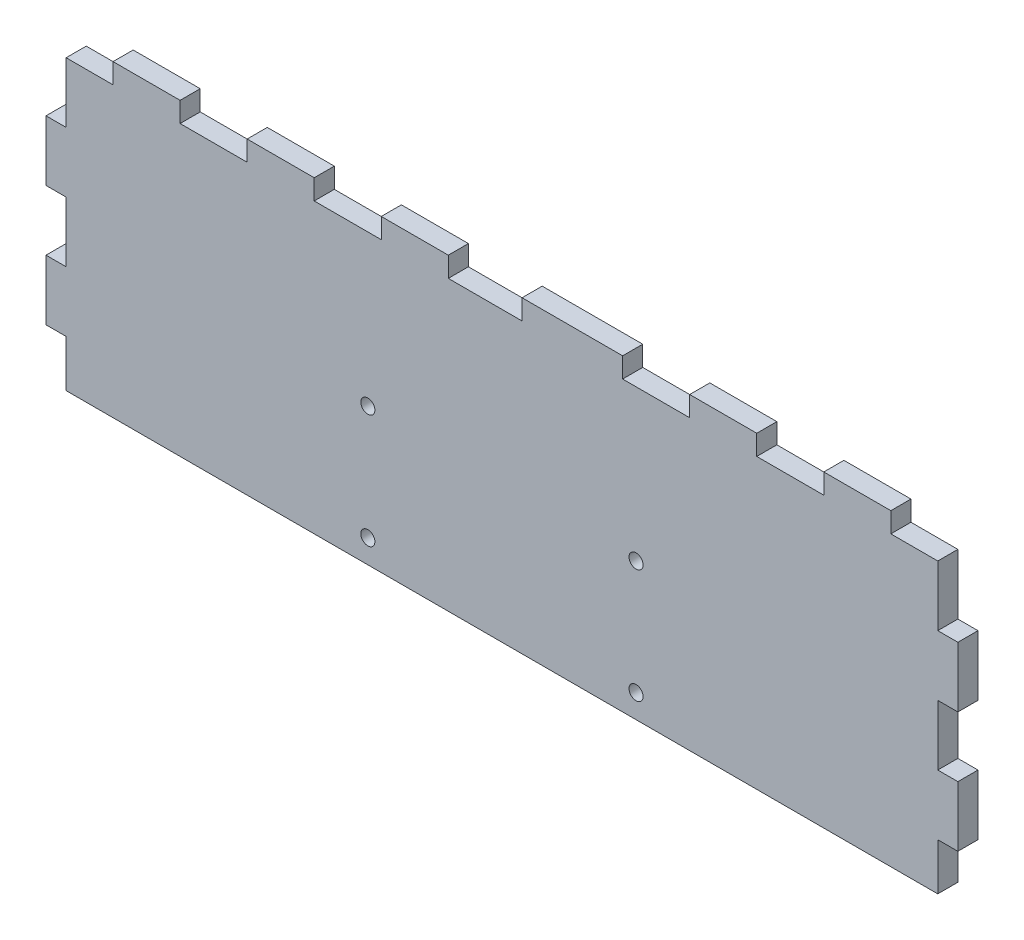
from build123d import *

# Parameters (mm, degrees)
SKETCH1_W           = 136
SKETCH1_H           = 46
SKETCH1_R           = 1.05
BOSS_EXTRUDE1_DEPTH = 3
CUT_EXTRUDE1_REACH  = 5
SKETCH4_W           = 3
SKETCH4_H           = 9
SKETCH4_H_2         = 7
SKETCH4_W_2         = 10
SKETCH4_H_3         = 3
SKETCH4_W_3         = 11


with BuildPart() as part:
    # Sketch1 → Boss-Extrude1 (new body)
    with BuildSketch(Plane.XY):
        with Locations((68, 23)):
            Rectangle(SKETCH1_W, SKETCH1_H)
        with Locations((88, 20.5)):
            Circle(SKETCH1_R, mode=Mode.SUBTRACT)
        with Locations((48, 20.5)):
            Circle(SKETCH1_R, mode=Mode.SUBTRACT)
        with Locations((48, 3.5)):
            Circle(SKETCH1_R, mode=Mode.SUBTRACT)
        with Locations((88, 3.5)):
            Circle(SKETCH1_R, mode=Mode.SUBTRACT)
    extrude(amount=BOSS_EXTRUDE1_DEPTH)

    # Sketch4 → Cut-Extrude1 (cut, up to next)
    with BuildSketch(Plane.XY.offset(3), mode=Mode.PRIVATE) as cut_extrude1_sk1:
        Polygon((0, 46), (0, 43), (3, 43), (10, 43), (10, 46), align=None)
    cut_extrude1_tool1 = extrude(cut_extrude1_sk1.sketch, amount=-CUT_EXTRUDE1_REACH, mode=Mode.PRIVATE) & part.part
    add(cut_extrude1_tool1.solids().sort_by_distance((5, 44.5, 3))[0], mode=Mode.SUBTRACT)
    # Sketch4 → Cut-Extrude1 (cut, up to next)
    with BuildSketch(Plane.XY.offset(3), mode=Mode.PRIVATE) as cut_extrude1_sk2:
        with Locations((1.5, 38.5)):
            Rectangle(SKETCH4_W, SKETCH4_H)
    cut_extrude1_tool2 = extrude(cut_extrude1_sk2.sketch, amount=-CUT_EXTRUDE1_REACH, mode=Mode.PRIVATE) & part.part
    add(cut_extrude1_tool2.solids().sort_by_distance((1.5, 38.5, 3))[0], mode=Mode.SUBTRACT)
    # Sketch4 → Cut-Extrude1 (cut, up to next)
    with BuildSketch(Plane.XY.offset(3), mode=Mode.PRIVATE) as cut_extrude1_sk3:
        with Locations((1.5, 20.5)):
            Rectangle(SKETCH4_W, SKETCH4_H)
    cut_extrude1_tool3 = extrude(cut_extrude1_sk3.sketch, amount=-CUT_EXTRUDE1_REACH, mode=Mode.PRIVATE) & part.part
    add(cut_extrude1_tool3.solids().sort_by_distance((1.5, 20.5, 3))[0], mode=Mode.SUBTRACT)
    # Sketch4 → Cut-Extrude1 (cut, up to next)
    with BuildSketch(Plane.XY.offset(3), mode=Mode.PRIVATE) as cut_extrude1_sk4:
        with Locations((1.5, 3.5)):
            Rectangle(SKETCH4_W, SKETCH4_H_2)
    cut_extrude1_tool4 = extrude(cut_extrude1_sk4.sketch, amount=-CUT_EXTRUDE1_REACH, mode=Mode.PRIVATE) & part.part
    add(cut_extrude1_tool4.solids().sort_by_distance((1.5, 3.5, 3))[0], mode=Mode.SUBTRACT)
    # Sketch4 → Cut-Extrude1 (cut, up to next)
    with BuildSketch(Plane.XY.offset(3), mode=Mode.PRIVATE) as cut_extrude1_sk5:
        with Locations((25, 44.5)):
            Rectangle(SKETCH4_W_2, SKETCH4_H_3)
    cut_extrude1_tool5 = extrude(cut_extrude1_sk5.sketch, amount=-CUT_EXTRUDE1_REACH, mode=Mode.PRIVATE) & part.part
    add(cut_extrude1_tool5.solids().sort_by_distance((25, 44.5, 3))[0], mode=Mode.SUBTRACT)
    # Sketch4 → Cut-Extrude1 (cut, up to next)
    with BuildSketch(Plane.XY.offset(3), mode=Mode.PRIVATE) as cut_extrude1_sk6:
        with Locations((45, 44.5)):
            Rectangle(SKETCH4_W_2, SKETCH4_H_3)
    cut_extrude1_tool6 = extrude(cut_extrude1_sk6.sketch, amount=-CUT_EXTRUDE1_REACH, mode=Mode.PRIVATE) & part.part
    add(cut_extrude1_tool6.solids().sort_by_distance((45, 44.5, 3))[0], mode=Mode.SUBTRACT)
    # Sketch4 → Cut-Extrude1 (cut, up to next)
    with BuildSketch(Plane.XY.offset(3), mode=Mode.PRIVATE) as cut_extrude1_sk7:
        with Locations((65.5, 44.5)):
            Rectangle(SKETCH4_W_3, SKETCH4_H_3)
    cut_extrude1_tool7 = extrude(cut_extrude1_sk7.sketch, amount=-CUT_EXTRUDE1_REACH, mode=Mode.PRIVATE) & part.part
    add(cut_extrude1_tool7.solids().sort_by_distance((65.5, 44.5, 3))[0], mode=Mode.SUBTRACT)
    # Sketch4 → Cut-Extrude1 (cut, up to next)
    with BuildSketch(Plane.XY.offset(3), mode=Mode.PRIVATE) as cut_extrude1_sk8:
        with Locations((91, 44.5)):
            Rectangle(SKETCH4_W_2, SKETCH4_H_3)
    cut_extrude1_tool8 = extrude(cut_extrude1_sk8.sketch, amount=-CUT_EXTRUDE1_REACH, mode=Mode.PRIVATE) & part.part
    add(cut_extrude1_tool8.solids().sort_by_distance((91, 44.5, 3))[0], mode=Mode.SUBTRACT)
    # Sketch4 → Cut-Extrude1 (cut, up to next)
    with BuildSketch(Plane.XY.offset(3), mode=Mode.PRIVATE) as cut_extrude1_sk9:
        with Locations((111, 44.5)):
            Rectangle(SKETCH4_W_2, SKETCH4_H_3)
    cut_extrude1_tool9 = extrude(cut_extrude1_sk9.sketch, amount=-CUT_EXTRUDE1_REACH, mode=Mode.PRIVATE) & part.part
    add(cut_extrude1_tool9.solids().sort_by_distance((111, 44.5, 3))[0], mode=Mode.SUBTRACT)
    # Sketch4 → Cut-Extrude1 (cut, up to next)
    with BuildSketch(Plane.XY.offset(3), mode=Mode.PRIVATE) as cut_extrude1_sk10:
        Polygon((133, 43), (136, 43), (136, 46), (126, 46), (126, 43), align=None)
    cut_extrude1_tool10 = extrude(cut_extrude1_sk10.sketch, amount=-CUT_EXTRUDE1_REACH, mode=Mode.PRIVATE) & part.part
    add(cut_extrude1_tool10.solids().sort_by_distance((131, 44.5, 3))[0], mode=Mode.SUBTRACT)
    # Sketch4 → Cut-Extrude1 (cut, up to next)
    with BuildSketch(Plane.XY.offset(3), mode=Mode.PRIVATE) as cut_extrude1_sk11:
        with Locations((134.5, 38.5)):
            Rectangle(SKETCH4_W, SKETCH4_H)
    cut_extrude1_tool11 = extrude(cut_extrude1_sk11.sketch, amount=-CUT_EXTRUDE1_REACH, mode=Mode.PRIVATE) & part.part
    add(cut_extrude1_tool11.solids().sort_by_distance((134.5, 38.5, 3))[0], mode=Mode.SUBTRACT)
    # Sketch4 → Cut-Extrude1 (cut, up to next)
    with BuildSketch(Plane.XY.offset(3), mode=Mode.PRIVATE) as cut_extrude1_sk12:
        with Locations((134.5, 20.5)):
            Rectangle(SKETCH4_W, SKETCH4_H)
    cut_extrude1_tool12 = extrude(cut_extrude1_sk12.sketch, amount=-CUT_EXTRUDE1_REACH, mode=Mode.PRIVATE) & part.part
    add(cut_extrude1_tool12.solids().sort_by_distance((134.5, 20.5, 3))[0], mode=Mode.SUBTRACT)
    # Sketch4 → Cut-Extrude1 (cut, up to next)
    with BuildSketch(Plane.XY.offset(3), mode=Mode.PRIVATE) as cut_extrude1_sk13:
        with Locations((134.5, 3.5)):
            Rectangle(SKETCH4_W, SKETCH4_H_2)
    cut_extrude1_tool13 = extrude(cut_extrude1_sk13.sketch, amount=-CUT_EXTRUDE1_REACH, mode=Mode.PRIVATE) & part.part
    add(cut_extrude1_tool13.solids().sort_by_distance((134.5, 3.5, 3))[0], mode=Mode.SUBTRACT)


solid = part.part
